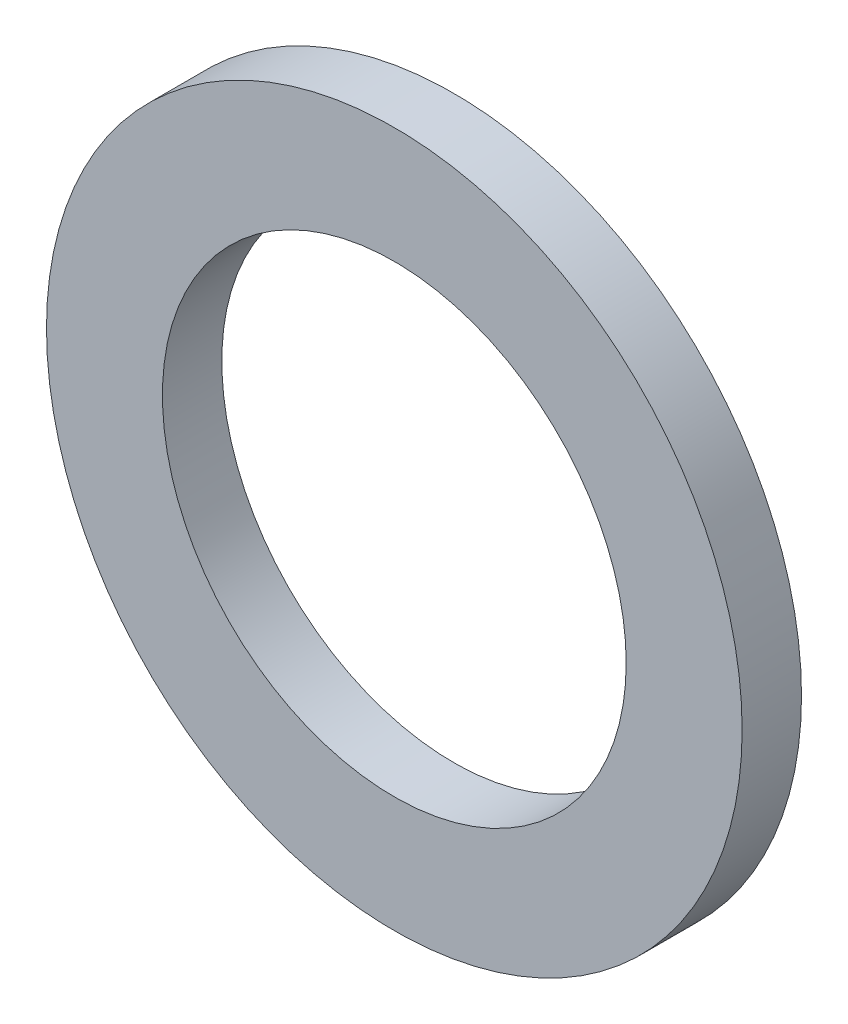
from build123d import *

# Parameters (mm, degrees)
SKETCH1_W = 0.79375
SKETCH1_H = 0.4064


with BuildPart() as part:
    # Sketch1 → Revolve1 (revolve)
    with BuildSketch(Plane(origin=(0, 0, 0), x_dir=(1, 0, 0), z_dir=(0, 1, 0))):
        with Locations((1.984375, -0.2032)):
            Rectangle(SKETCH1_W, SKETCH1_H)
    revolve(axis=Axis((0, 0, 0), (0, 0, 1)))


solid = part.part
